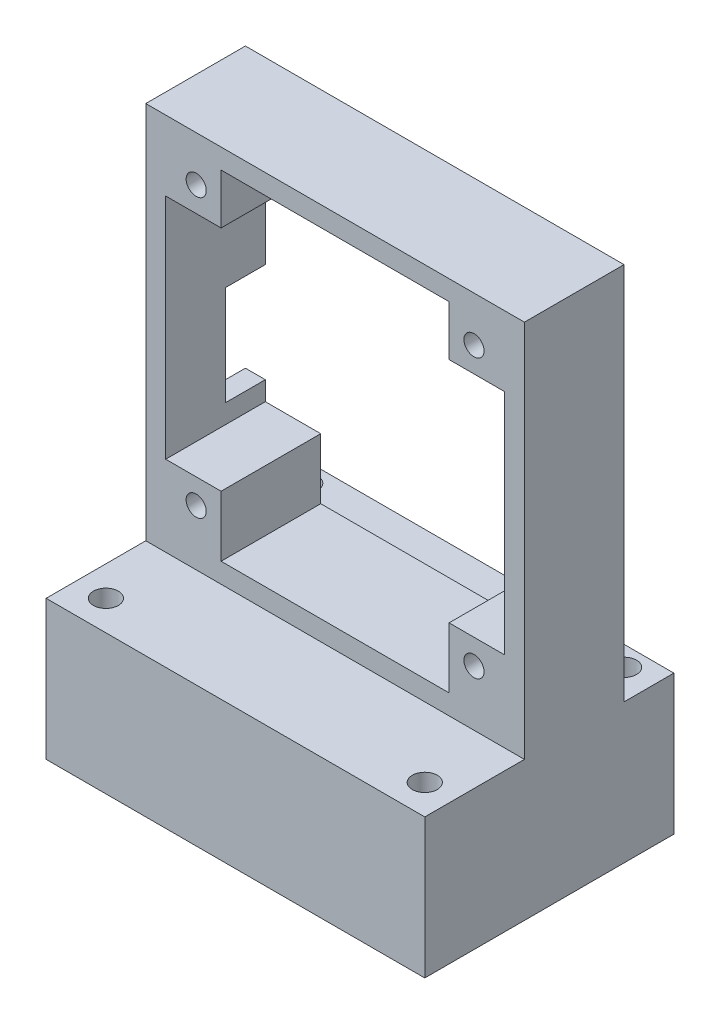
from build123d import *

# Parameters (mm, degrees)
SKETCH1_W           = 38
SKETCH1_H           = 30
BOSS_EXTRUDE1_DEPTH = 14
SKETCH2_W           = 38
SKETCH2_H           = 10
BOSS_EXTRUDE2_DEPTH = 38
SKETCH3_R           = 1.01
CUT_EXTRUDE1_DEPTH  = 38
CUT_EXTRUDE2_DEPTH  = 38
SKETCH5_W           = 4
SKETCH5_H           = 10
CUT_EXTRUDE3_DEPTH  = 12
SKETCH6_R           = 1.25
CUT_EXTRUDE4_DEPTH  = 31
SKETCH8_W           = 38
SKETCH8_H           = 5
CUT_EXTRUDE5_DEPTH  = 31


with BuildPart() as part:
    # Sketch1 → Boss-Extrude1 (new body)
    with BuildSketch(Plane(origin=(0, 0, 0), x_dir=(1, 0, 0), z_dir=(0, 1, 0))):
        with Locations((2.714285714, 1.989417989)):
            Rectangle(SKETCH1_W, SKETCH1_H)
    extrude(amount=BOSS_EXTRUDE1_DEPTH)

    # Sketch2 → Boss-Extrude2 (add)
    with BuildSketch(Plane(origin=(0, 14, 0), x_dir=(1, 0, 0), z_dir=(0, 1, 0))):
        with Locations((2.714285714, 1.989417989)):
            Rectangle(SKETCH2_W, SKETCH2_H)
    extrude(amount=BOSS_EXTRUDE2_DEPTH)

    # Sketch3 → Cut-Extrude1 (cut)
    with BuildSketch(Plane(origin=(0, 0, -6.989417989), x_dir=(-1, 0, 0), z_dir=(0, 0, -1))):
        with Locations((-16.654285714, 47.466668182)):
            Circle(SKETCH3_R)
        with Locations((11.225714286, 47.466668182)):
            Circle(SKETCH3_R)
        with Locations((-16.654285714, 19.586668182)):
            Circle(SKETCH3_R)
        with Locations((11.225714286, 19.586668182)):
            Circle(SKETCH3_R)
    extrude(amount=-CUT_EXTRUDE1_DEPTH, mode=Mode.SUBTRACT)

    # Sketch4 → Cut-Extrude2 (cut)
    with BuildSketch(Plane(origin=(0, 0, -6.989417989), x_dir=(-1, 0, 0), z_dir=(0, 0, -1))):
        Polygon((-14.154285714, 47.396812474), (-14.154285714, 50), (8.725714286, 50), (8.725714286, 44.966668182), (14.285714286, 44.966668182), (14.285714286, 22.086668182), (8.725714286, 22.086668182), (8.725714286, 16), (-14.154285714, 16), (-14.154285714, 22.086668182), (-19.714285714, 22.086668182), (-19.714285714, 44.966668182), (-14.154285714, 44.966668182), align=None)
    extrude(amount=-CUT_EXTRUDE2_DEPTH, mode=Mode.SUBTRACT)

    # Sketch5 → Cut-Extrude3 (cut)
    with BuildSketch(Plane.ZY.offset(16.285714286)):
        with Locations((-4.989417989, 29)):
            Rectangle(SKETCH5_W, SKETCH5_H)
    extrude(amount=-CUT_EXTRUDE3_DEPTH, mode=Mode.SUBTRACT)

    # Sketch6 → Cut-Extrude4 (cut)
    with BuildSketch(Plane(origin=(0, 14, 0), x_dir=(1, 0, 0), z_dir=(0, 1, 0))):
        with Locations((-13.285714286, 9.989417989)):
            Circle(SKETCH6_R)
        with Locations((18.714285714, 9.989417989)):
            Circle(SKETCH6_R)
        with Locations((18.714285714, -10.010582011)):
            Circle(SKETCH6_R)
        with Locations((-13.285714286, -10.010582011)):
            Circle(SKETCH6_R)
    extrude(amount=-CUT_EXTRUDE4_DEPTH, mode=Mode.SUBTRACT)

    # Sketch8 → Cut-Extrude5 (cut)
    with BuildSketch(Plane(origin=(0, 14, 0), x_dir=(1, 0, 0), z_dir=(0, 1, 0))):
        with Locations((2.714285714, 14.489417989)):
            Rectangle(SKETCH8_W, SKETCH8_H)
    extrude(amount=-CUT_EXTRUDE5_DEPTH, mode=Mode.SUBTRACT)


solid = part.part
